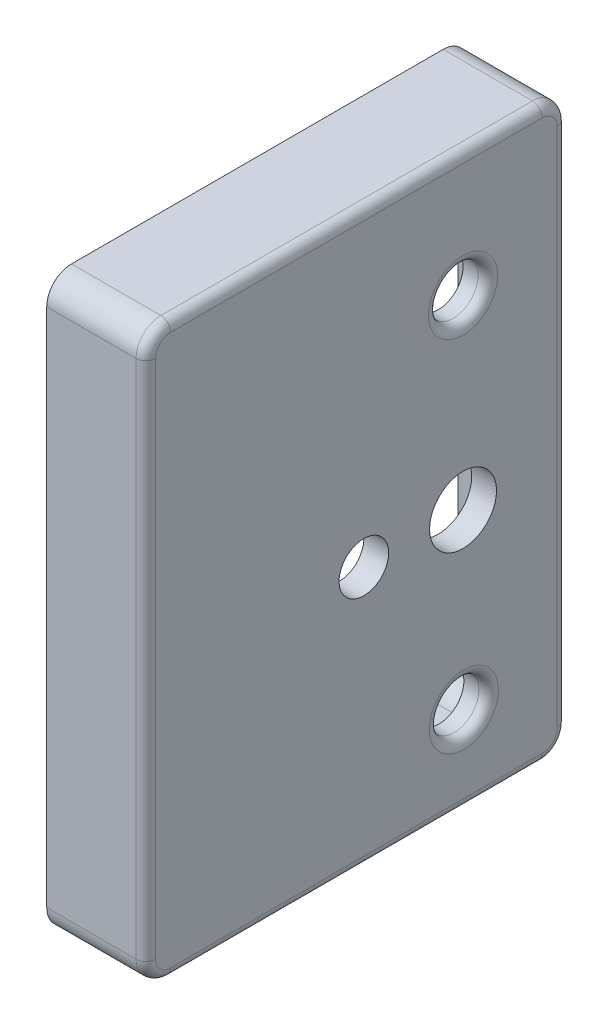
from build123d import *

# Parameters (mm, degrees)
SKETCH1_W           = 43.18
SKETCH1_H           = 58.42
BOSS_EXTRUDE1_DEPTH = 10.16
SKETCH2_R           = 2.54
SKETCH2_R_2         = 3.429
CUT_EXTRUDE2_DEPTH  = 11.16
SKETCH3_W           = 39.116
SKETCH3_H           = 54.356
CUT_EXTRUDE3_DEPTH  = 7.62
SKETCH4_W           = 41.148
SKETCH4_H           = 56.388
CUT_EXTRUDE4_DEPTH  = 3.81
FILLET1_R           = 2.54
FILLET2_R           = 2.54
FILLET3_R           = 2.54
FILLET4_R           = 2.54
FILLET5_R           = 2.54
FILLET6_R           = 1
FILLET7_R           = 1
FILLET8_R           = 1


with BuildPart() as part:
    # Sketch1 → Boss-Extrude1 (new body)
    with BuildSketch(Plane(origin=(0, 0, 0), x_dir=(0, 0, -1), z_dir=(1, 0, 0))):
        with Locations((6.948060942, 29.21)):
            Rectangle(SKETCH1_W, SKETCH1_H)
    extrude(amount=BOSS_EXTRUDE1_DEPTH)

    # Sketch2 → Cut-Extrude2 (cut, through all)
    with BuildSketch(Plane.ZY):
        with Locations((-17.96692562, 8.890014802)):
            Circle(SKETCH2_R)
        with Locations((-17.881082197, 45.719807571)):
            Circle(SKETCH2_R)
        with Locations((-17.881082197, 26.669807571)):
            Circle(SKETCH2_R_2)
        with Locations((-7.710060942, 26.669807571)):
            Circle(SKETCH2_R)
    extrude(amount=-CUT_EXTRUDE2_DEPTH, mode=Mode.SUBTRACT)

    # Sketch3 → Cut-Extrude3 (cut)
    with BuildSketch(Plane.ZY):
        with Locations((-6.948060942, 29.21)):
            Rectangle(SKETCH3_W, SKETCH3_H)
    extrude(amount=-CUT_EXTRUDE3_DEPTH, mode=Mode.SUBTRACT)

    # Sketch4 → Cut-Extrude4 (cut)
    with BuildSketch(Plane.ZY):
        with Locations((-6.948060942, 29.21)):
            Rectangle(SKETCH4_W, SKETCH4_H)
    extrude(amount=-CUT_EXTRUDE4_DEPTH, mode=Mode.SUBTRACT)

    # Fillet1
    fillet1_edges = [part.edges().sort_by_distance(p)[0] for p in [
        (5.715, 2.032, -26.506060942),
        (1.905, 1.016, -27.522060942),
    ]]
    fillet(fillet1_edges, radius=FILLET1_R)

    # Fillet2
    fillet2_edges = [part.edges().sort_by_distance(p)[0] for p in [
        (5.715, 2.032, 12.609939058),
        (1.905, 1.016, 13.625939058),
    ]]
    fillet(fillet2_edges, radius=FILLET2_R)

    # Fillet3
    fillet3_edges = [part.edges().sort_by_distance(p)[0] for p in [
        (5.715, 56.388, 12.609939058),
        (1.905, 57.404, 13.625939058),
    ]]
    fillet(fillet3_edges, radius=FILLET3_R)

    # Fillet4
    fillet4_edges = [part.edges().sort_by_distance(p)[0] for p in [
        (5.715, 56.388, -26.506060942),
        (1.905, 57.404, -27.522060942),
    ]]
    fillet(fillet4_edges, radius=FILLET4_R)

    # Fillet5
    fillet5_edges = [part.edges().sort_by_distance(p)[0] for p in [
        (5.08, 58.42, 14.641939058),
        (5.08, 58.42, -28.538060942),
        (5.08, 0, -28.538060942),
        (5.08, 0, 14.641939058),
    ]]
    fillet(fillet5_edges, radius=FILLET5_R)

    # Fillet6
    fillet6_edges = [part.edges().sort_by_distance(p)[0] for p in [
        (10.16, 29.21, -28.538060942),
        (10.16, 0, -6.948060942),
        (10.16, 29.21, 14.641939058),
        (10.16, 58.42, -6.948060942),
        (10.16, 57.676051224, 13.897990282),
        (10.16, 57.676051224, -27.794112166),
        (10.16, 0.743948776, 13.897990282),
        (10.16, 0.743948776, -27.794112166),
    ]]
    fillet(fillet6_edges, radius=FILLET6_R)

    # Fillet7
    fillet7_edges = [part.edges().sort_by_distance(p)[0] for p in [
        (10.16, 45.719807571, -20.421082197),
    ]]
    fillet(fillet7_edges, radius=FILLET7_R)

    # Fillet8
    fillet8_edges = [part.edges().sort_by_distance(p)[0] for p in [
        (10.16, 8.890014802, -20.50692562),
    ]]
    fillet(fillet8_edges, radius=FILLET8_R)


solid = part.part
